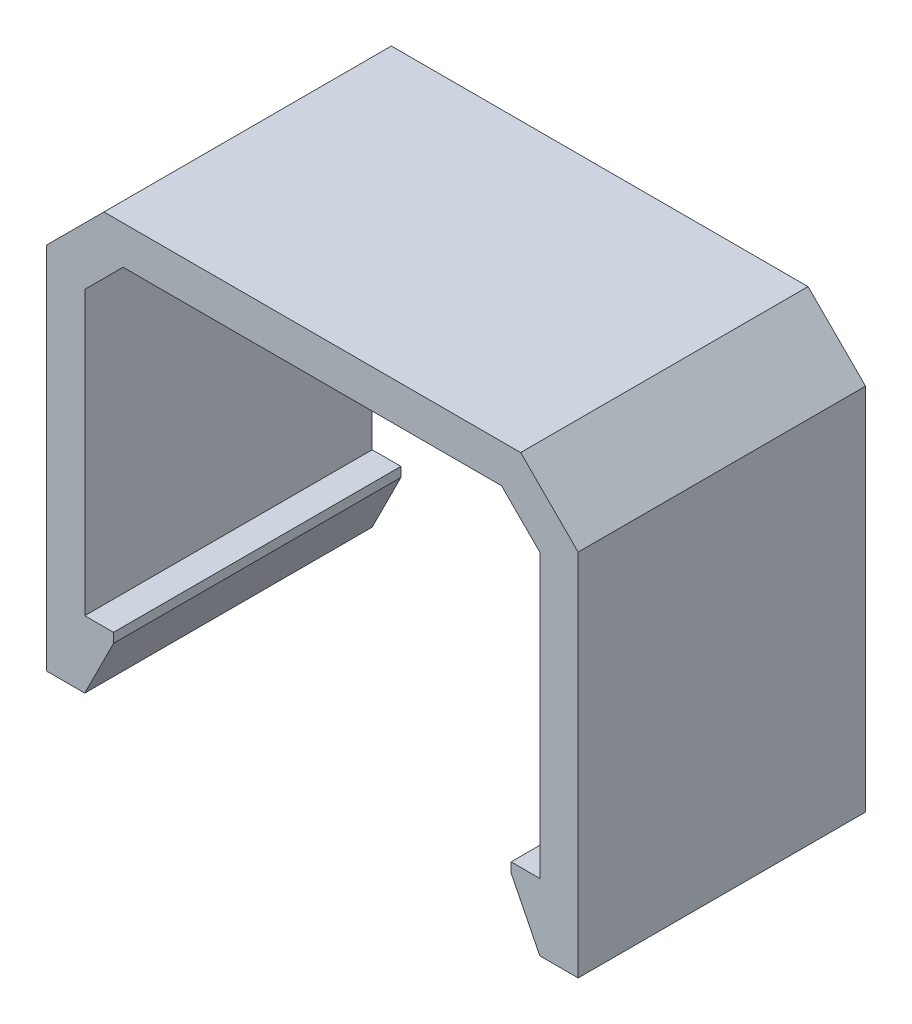
from build123d import *

# Parameters (mm, degrees)
BOSS_EXTRUDE1_DEPTH = 15
CHAMFER1_SIZE       = 3
CHAMFER2_SIZE       = 2
CHAMFER3_SIZE       = 1.5
CHAMFER3_SIZE2      = 3
CHAMFER4_SIZE       = 3
CHAMFER4_SIZE2      = 1.5


with BuildPart() as part:
    # Sketch1 → Boss-Extrude1 (new body)
    with BuildSketch(Plane.XY):
        Polygon((1.5, 0), (0, 0), (0, 16.75), (11.875, 16.75), (11.875, 18.75), (-2, 18.75), (-2, -3.5), (1.5, -3.5), align=None)
        Polygon((11.875, 18.75), (11.875, 16.75), (23.75, 16.75), (23.75, 0), (22.25, 0), (22.25, -3.5), (25.75, -3.5), (25.75, 18.75), align=None)
    extrude(amount=BOSS_EXTRUDE1_DEPTH)

    # Chamfer1
    chamfer1_edges = [part.edges().sort_by_distance(p)[0] for p in [
        (25.75, 18.75, 7.5),
        (-2, 18.75, 7.5),
    ]]
    chamfer(chamfer1_edges, length=CHAMFER1_SIZE)

    # Chamfer2
    chamfer2_edges = [part.edges().sort_by_distance(p)[0] for p in [
        (23.75, 16.75, 7.5),
        (0, 16.75, 7.5),
    ]]
    chamfer(chamfer2_edges, length=CHAMFER2_SIZE)

    # Chamfer3
    chamfer3_edges = [part.edges().sort_by_distance(p)[0] for p in [
        (1.5, -3.5, 7.5),
    ]]
    chamfer3_side = [part.faces().sort_by_distance(p)[0] for p in [
        (-0.25, -3.5, 7.5),
    ]]
    chamfer(chamfer3_edges, length=CHAMFER3_SIZE, length2=CHAMFER3_SIZE2, reference=chamfer3_side[0])

    # Chamfer4
    chamfer4_edges = [part.edges().sort_by_distance(p)[0] for p in [
        (22.25, -3.5, 7.5),
    ]]
    chamfer4_side = [part.faces().sort_by_distance(p)[0] for p in [
        (22.25, -1.75, 7.5),
    ]]
    chamfer(chamfer4_edges, length=CHAMFER4_SIZE, length2=CHAMFER4_SIZE2, reference=chamfer4_side[0])


solid = part.part
